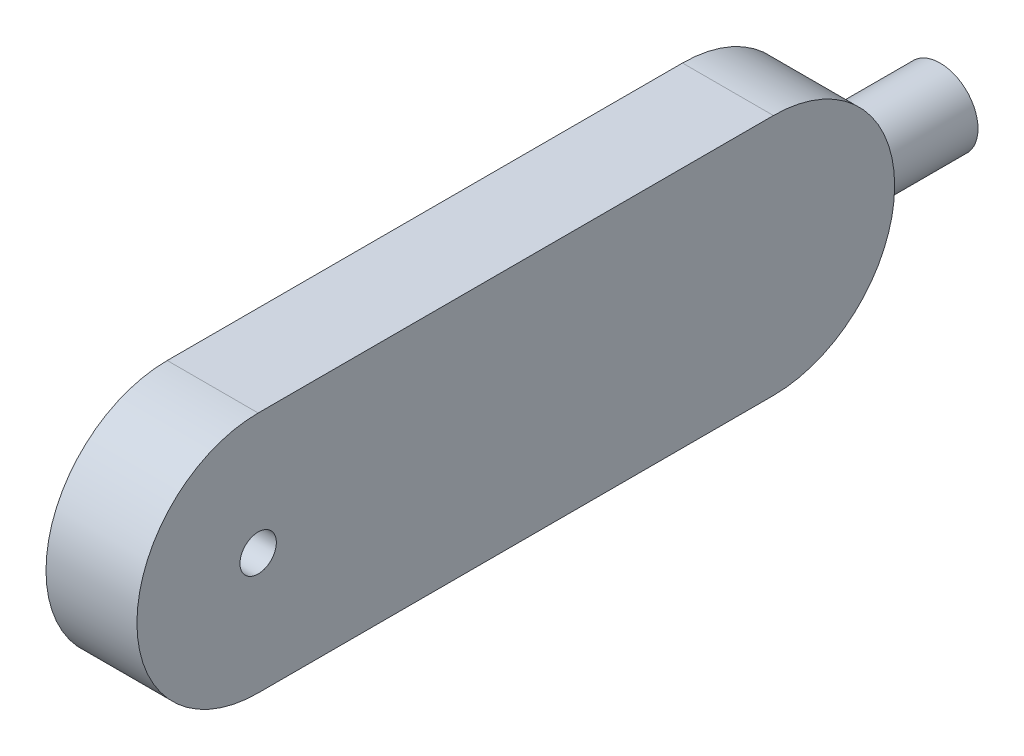
from build123d import *

# Parameters (mm, degrees)
SKETCH2_W               = 250
SKETCH2_H               = 80
BOSS_EXTRUDE1_DEPTH     = 30
SKETCH11_R              = 6
CUT_EXTRUDE2_DEPTH      = 265.196896272
CUT_EXTRUDE_THIN2_DEPTH = 265.196896272
SKETCH15_W              = 40
SKETCH15_H              = 20
CUT_EXTRUDE3_DEPTH      = 25
SKETCH16_R              = 12.5
BOSS_EXTRUDE2_DEPTH     = 50


with BuildPart() as part:
    # Sketch2 → Boss-Extrude1 (new body)
    with BuildSketch(Plane(origin=(0, 0, 0), x_dir=(0, 0, -1), z_dir=(1, 0, 0))):
        with Locations((125, 40)):
            Rectangle(SKETCH2_W, SKETCH2_H)
    extrude(amount=BOSS_EXTRUDE1_DEPTH)

    # Sketch11 → Cut-Extrude2 (cut, through all)
    with BuildSketch(Plane(origin=(30, 0, 0), x_dir=(0, 0, -1), z_dir=(1, 0, 0))):
        with Locations((40, 40)):
            Circle(SKETCH11_R)
    extrude(amount=-CUT_EXTRUDE2_DEPTH, mode=Mode.SUBTRACT)

    # Sketch14 → Cut-Extrude-Thin2 (cut, through all)
    with BuildSketch(Plane.ZY):
        with BuildLine():
            ThreePointArc((-40, 0), (0, 40), (-40, 80))
            Line((-40, 80), (-40, 90))
            ThreePointArc((-40, 90), (10, 40), (-40, -10))
            Line((-40, -10), (-40, 0))
        make_face()
        with BuildLine():
            ThreePointArc((-210, 80), (-250, 40), (-210, 0))
            Line((-210, 0), (-210, -10))
            ThreePointArc((-210, -10), (-260, 40), (-210, 90))
            Line((-210, 90), (-210, 80))
        make_face()
    extrude(amount=-CUT_EXTRUDE_THIN2_DEPTH, mode=Mode.SUBTRACT)


with BuildPart() as cut_extrude_thin2_kept_piece:
    # of the separate pieces the step leaves, the one the design keeps (cut_extrude_thin2_pieces_kept)
    add(part.part.solids().sort_by_distance((0, 0, -40))[0])

    # Sketch15 → Cut-Extrude3 (cut)
    with BuildSketch(Plane.ZY):
        with Locations((-210, 40)):
            Rectangle(SKETCH15_W, SKETCH15_H)
    extrude(amount=-CUT_EXTRUDE3_DEPTH, mode=Mode.SUBTRACT)

    # Sketch16 → Boss-Extrude2 (add)
    with BuildSketch(Plane(origin=(0, 0, -230), x_dir=(-1, 0, 0), z_dir=(0, 0, -1))):
        with Locations(Location((-15, 40, 0), (0, 0, 180))):
            Circle(SKETCH16_R)
    extrude(amount=BOSS_EXTRUDE2_DEPTH)


solid = cut_extrude_thin2_kept_piece.part
